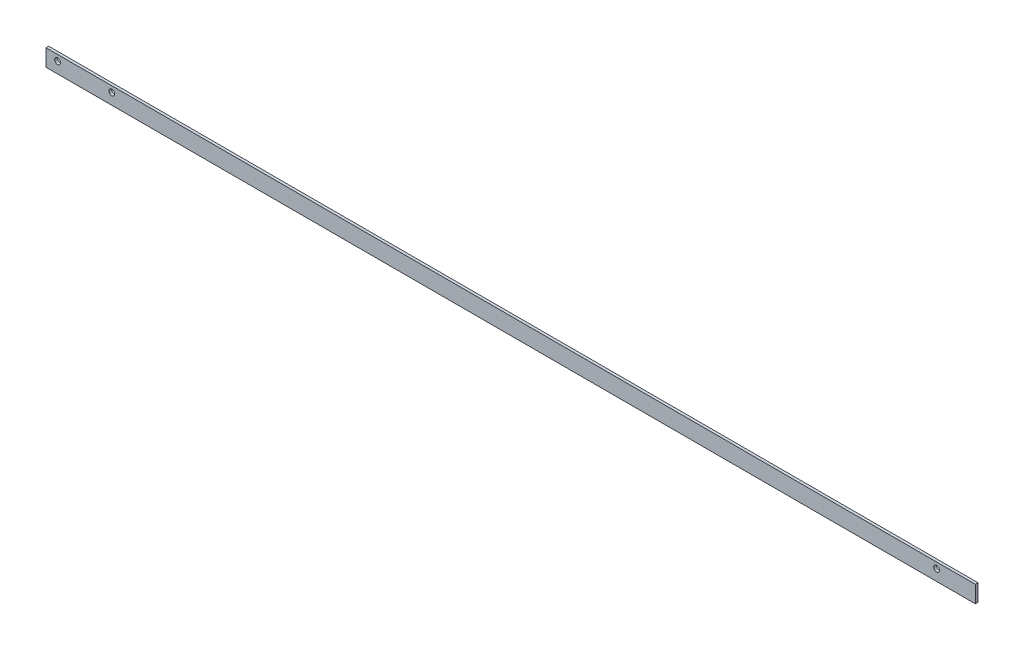
from build123d import *

# Parameters (mm, degrees)
SKETCH1_W             = 609.6
SKETCH1_H             = 11.0998
BOSS_EXTRUDE1_DEPTH   = 0.889
F_6_CLEARANCE_HOLE1_D = 3.7973


with BuildPart() as part:
    # Sketch1 → Boss-Extrude1 (new body, symmetric)
    with BuildSketch(Plane.XY):
        Rectangle(SKETCH1_W, SKETCH1_H)
    extrude(amount=BOSS_EXTRUDE1_DEPTH, both=True)

    # #6 Clearance Hole1 (through all)
    with Locations(Plane.XY.offset(0.889)):
        with Locations((-297.18, 1.7399), (-261.62, 1.7399), (279.4, 1.7399)):
            Hole(F_6_CLEARANCE_HOLE1_D / 2)


solid = part.part
